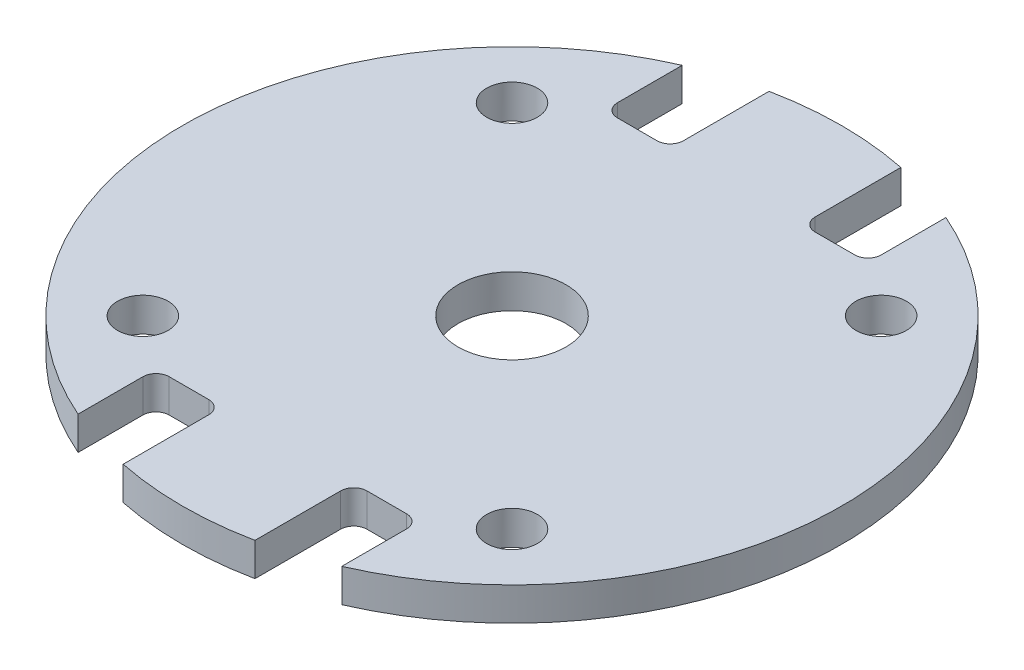
from build123d import *
from build123d.topology import SkipClean

# Parameters (mm, degrees)
BOSS_EXTRUDE1_DEPTH   = 0.8
SKETCH4_R             = 2.6
CUT_EXTRUDE1_DEPTH    = 23.507582056
F_2_CLEARANCE_HOLE1_D = 2.4384
SKETCH5_R             = 1.905
SKETCH5_R_2           = 1.2192
SKETCH5_R_3           = 3.81
SKETCH5_R_4           = 2.6
BOSS_EXTRUDE2_DEPTH   = 0.0254


with BuildPart() as part:
    # Sketch1 → Boss-Extrude1 (new, symmetric)
    with BuildSketch(Plane(origin=(0, 0, 0), x_dir=(1, 0, 0), z_dir=(0, 1, 0))):
        with BuildLine():
            Line((-6.35, 14.549677831), (-6.35, 11.43))
            ThreePointArc((-6.35, 11.43), (-6.164012806, 10.980987194), (-5.715, 10.795))
            Line((-5.715, 10.795), (-3.81, 10.795))
            ThreePointArc((-3.81, 10.795), (-3.360987194, 10.980987194), (-3.175, 11.43))
            Line((-3.175, 11.43), (-3.175, 15.554259867))
            ThreePointArc((-3.175, 15.554259867), (0, 15.875), (3.175, 15.554259867))
            Line((3.175, 15.554259867), (3.175, 11.43))
            ThreePointArc((3.175, 11.43), (3.360987194, 10.980987194), (3.81, 10.795))
            Line((3.81, 10.795), (5.715, 10.795))
            ThreePointArc((5.715, 10.795), (6.164012806, 10.980987194), (6.35, 11.43))
            Line((6.35, 11.43), (6.35, 14.549677831))
            ThreePointArc((6.35, 14.549677831), (15.875, 0), (6.35, -14.549677831))
            Line((6.35, -14.549677831), (6.35, -11.43))
            ThreePointArc((6.35, -11.43), (6.164012806, -10.980987194), (5.715, -10.795))
            Line((5.715, -10.795), (3.81, -10.795))
            ThreePointArc((3.81, -10.795), (3.360987194, -10.980987194), (3.175, -11.43))
            Line((3.175, -11.43), (3.175, -15.554259867))
            ThreePointArc((3.175, -15.554259867), (0, -15.875), (-3.175, -15.554259867))
            Line((-3.175, -15.554259867), (-3.175, -11.43))
            ThreePointArc((-3.175, -11.43), (-3.360987194, -10.980987194), (-3.81, -10.795))
            Line((-3.81, -10.795), (-5.715, -10.795))
            ThreePointArc((-5.715, -10.795), (-6.164012806, -10.980987194), (-6.35, -11.43))
            Line((-6.35, -11.43), (-6.35, -14.549677831))
            ThreePointArc((-6.35, -14.549677831), (-15.875, 0), (-6.35, 14.549677831))
        make_face()
    extrude(amount=BOSS_EXTRUDE1_DEPTH, both=True)

    # Sketch4 → Cut-Extrude1 (cut, through all)
    with BuildSketch(Plane(origin=(0, 0.8, 0), x_dir=(1, 0, 0), z_dir=(0, 1, 0))):
        with Locations(Location((0, 0, 0), (0, 0, 270))):
            Circle(SKETCH4_R)
    extrude(amount=-CUT_EXTRUDE1_DEPTH, mode=Mode.SUBTRACT)

    # #2 Clearance Hole1 (through all)
    with Locations(Plane(origin=(0, 0.8, 0), x_dir=(1, 0, 0), z_dir=(0, 1, 0))):
        with Locations((-8.89, 8.89), (8.89, 8.89), (-8.89, -8.89), (8.89, -8.89)):
            Hole(F_2_CLEARANCE_HOLE1_D / 2)

    # Sketch5 → Boss-Extrude2 (add)
    with SkipClean():  # the faces are left unmerged after this step: merging them gives an invalid solid
        with BuildSketch(Plane.XZ.offset(0.8)):
            with Locations(Location((-8.89, 8.89, 0), (0, 0, 90))):
                Circle(SKETCH5_R)
            with Locations(Location((-8.89, 8.89, 0), (0, 0, 90))):
                Circle(SKETCH5_R_2, mode=Mode.SUBTRACT)
            with Locations(Location((8.89, 8.89, 0), (0, 0, 90))):
                Circle(SKETCH5_R)
            with Locations(Location((8.89, 8.89, 0), (0, 0, 90))):
                Circle(SKETCH5_R_2, mode=Mode.SUBTRACT)
            with Locations(Location((8.89, -8.89, 0), (0, 0, 90))):
                Circle(SKETCH5_R)
            with Locations(Location((8.89, -8.89, 0), (0, 0, 90))):
                Circle(SKETCH5_R_2, mode=Mode.SUBTRACT)
            with Locations(Location((-8.89, -8.89, 0), (0, 0, 90))):
                Circle(SKETCH5_R)
            with Locations(Location((-8.89, -8.89, 0), (0, 0, 90))):
                Circle(SKETCH5_R_2, mode=Mode.SUBTRACT)
            with Locations(Location((0, 0, 0), (0, 0, 90))):
                Circle(SKETCH5_R_3)
            with Locations(Location((0, 0, 0), (0, 0, 90))):
                Circle(SKETCH5_R_4, mode=Mode.SUBTRACT)
        extrude(amount=BOSS_EXTRUDE2_DEPTH)


solid = part.part
